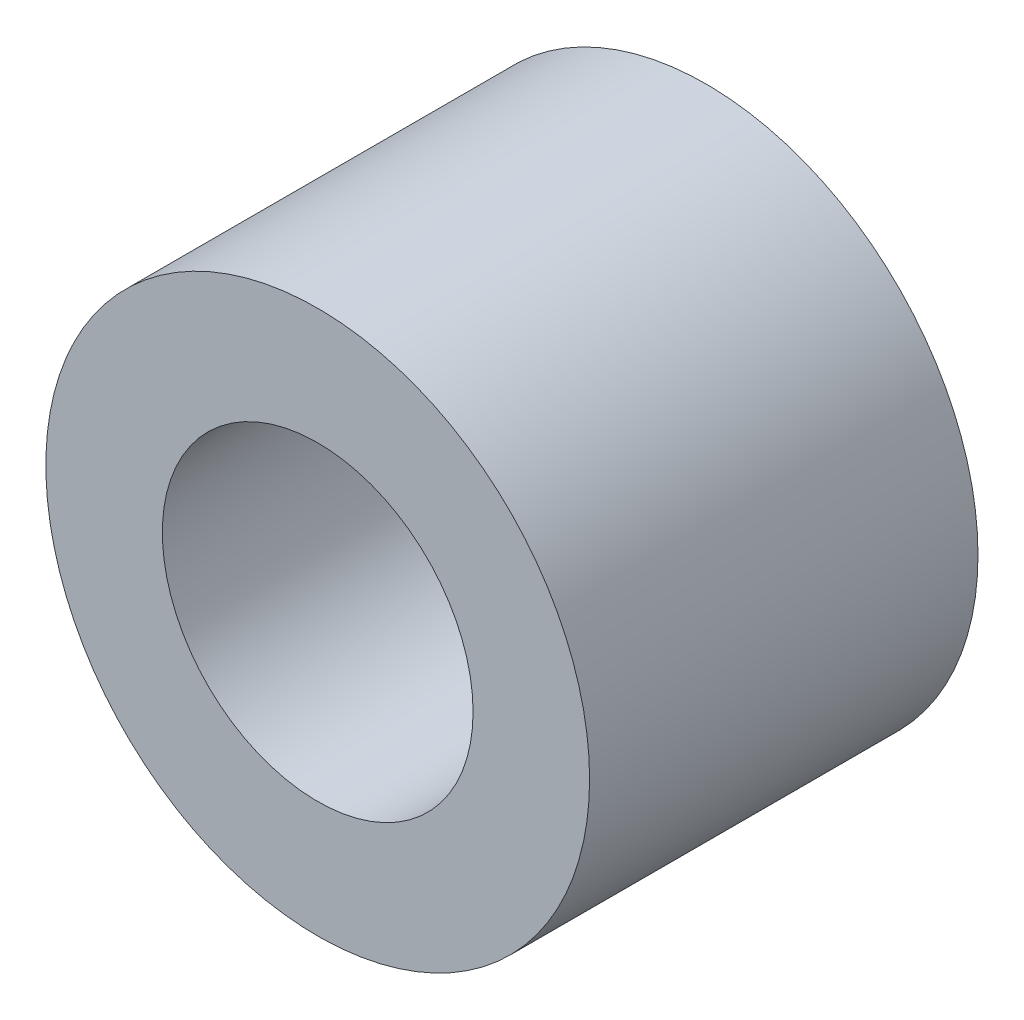
from build123d import *

# Parameters (mm, degrees)
SKETCH1_R           = 7
SKETCH1_R_2         = 4
BOSS_EXTRUDE1_DEPTH = 10


with BuildPart() as part:
    # Sketch1 → Boss-Extrude1 (new body)
    with BuildSketch(Plane.XY):
        Circle(SKETCH1_R)
        Circle(SKETCH1_R_2, mode=Mode.SUBTRACT)
    extrude(amount=BOSS_EXTRUDE1_DEPTH)


solid = part.part
